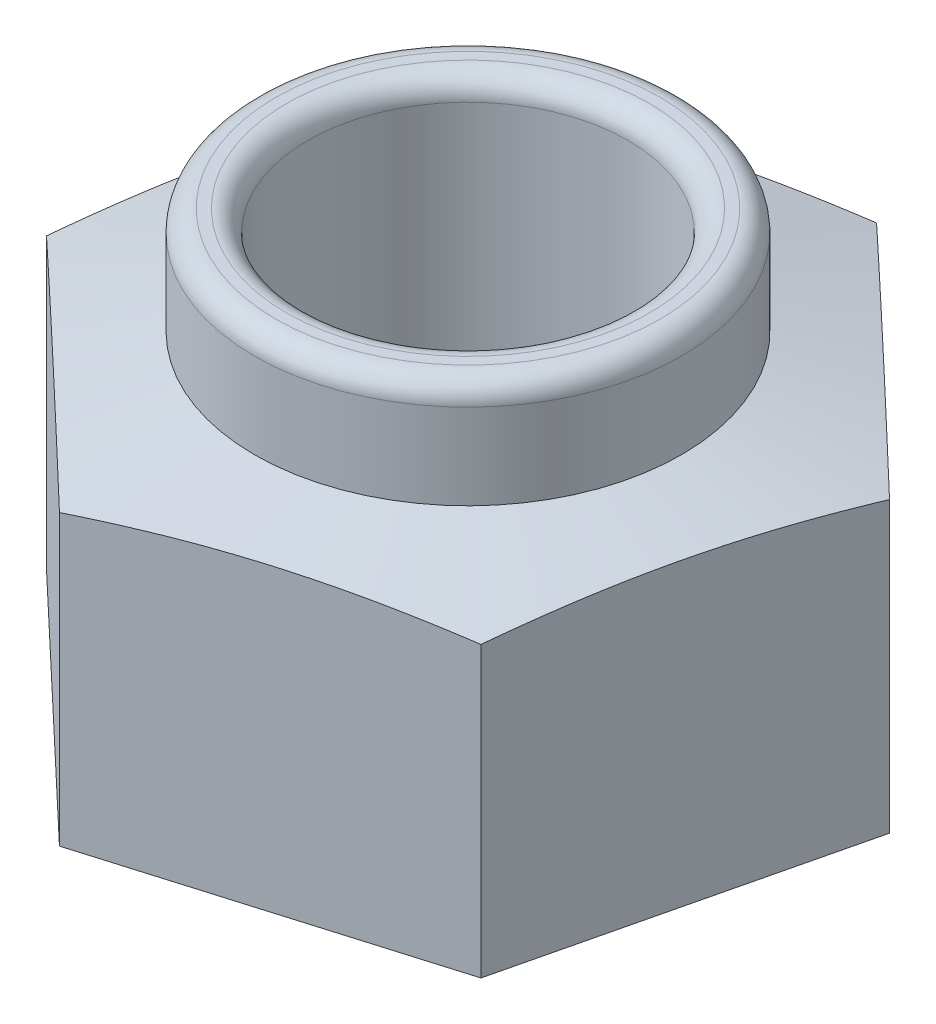
from build123d import *

# Parameters (mm, degrees)
SKETCH_1_R      = 1.5
EXTRUDE_1_DEPTH = 4
FILLET_2_R      = 0.2


with BuildPart() as part:
    # 草图1 → 凸台-拉伸1 (new body)
    with BuildSketch(Plane(origin=(0, 0, 0), x_dir=(1, 0, 0), z_dir=(0, 1, 0))):
        Polygon((2.305209376, -2.183882567), (3.04390247, 0.904428597), (0.738693094, 3.088311164), (-2.305209376, 2.183882567), (-3.04390247, -0.904428597), (-0.738693094, -3.088311164), align=None)
        Circle(SKETCH_1_R, mode=Mode.SUBTRACT)
    extrude(amount=EXTRUDE_1_DEPTH)

    # 草图2 → 切除-旋转1 (revolve, cut)
    with BuildSketch(Plane.XY):
        Polygon((-4, 2.5), (-2, 3), (-2, 4), (-4, 4), align=None)
    revolve(axis=Axis((0, 4, 0), (0, -1, 0)), mode=Mode.SUBTRACT)

    # 圆角2
    fillet_2_edges = [part.edges().sort_by_distance(p)[0] for p in [
        (-1.5, 4, 0),
        (2, 4, 0),
    ]]
    fillet(fillet_2_edges, radius=FILLET_2_R)


solid = part.part
